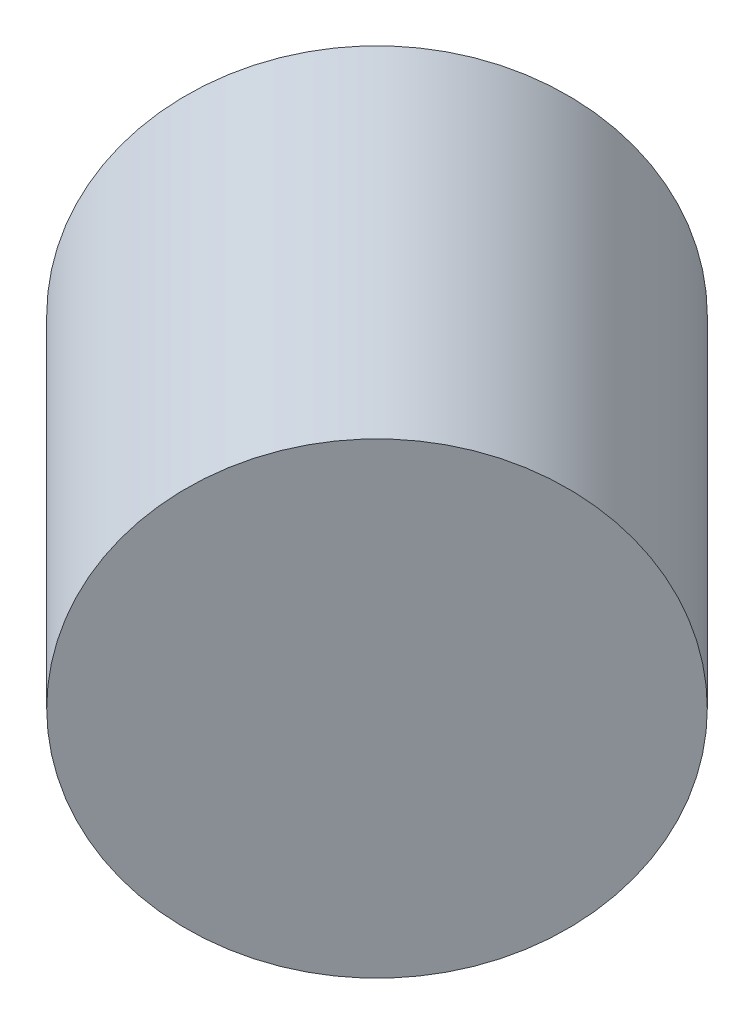
from build123d import *

# Parameters (mm, degrees)
SKETCH1_R           = 49
BOSS_EXTRUDE1_DEPTH = 101


with BuildPart() as part:
    # Sketch1 → Boss-Extrude1 (new body)
    with BuildSketch(Plane(origin=(-79.278576275, 0, -79.278576275), x_dir=(0.707106781, 0, -0.707106781), z_dir=(0.707106781, 0, 0.707106781))):
        with Locations((-226.167762387, -7.5)):
            Circle(SKETCH1_R)
    extrude(amount=-BOSS_EXTRUDE1_DEPTH)


solid = part.part
